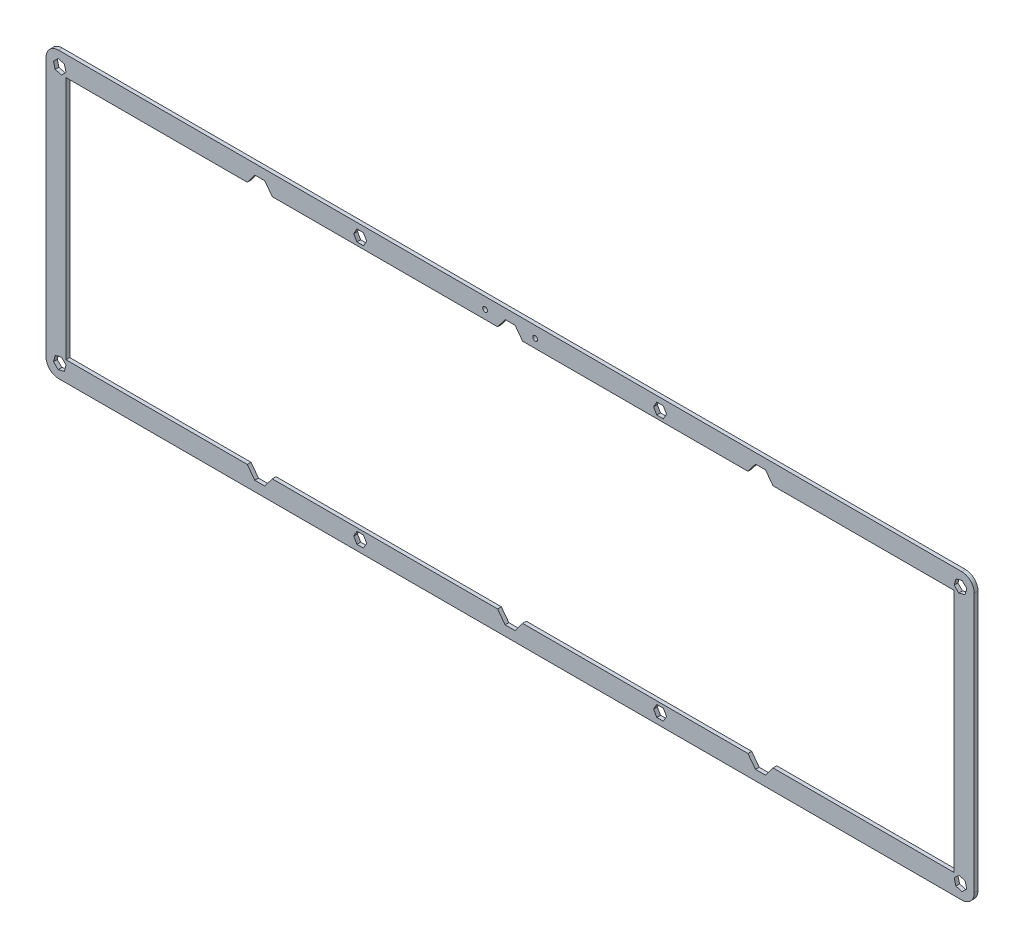
from build123d import *

# Parameters (mm, degrees)
MODEL_R             = 0.95
BOSS_EXTRUDE1_DEPTH = 1.5


with BuildPart() as part:
    # Model → Boss-Extrude1 (new body)
    with BuildSketch(Plane.XY):
        with BuildLine():
            Line((0, 108.6), (0, 5))
            ThreePointArc((0, 5), (1.464466094, 1.464466094), (5, 0))
            Line((5, 0), (365.775, 0))
            ThreePointArc((365.775, 0), (369.310533906, 1.464466094), (370.775, 5))
            Line((370.775, 5), (370.775, 108.6))
            ThreePointArc((370.775, 108.6), (369.310533906, 112.135533906), (365.775, 113.6))
            Line((365.775, 113.6), (5, 113.6))
            ThreePointArc((5, 113.6), (1.464466094, 112.135533906), (0, 108.6))
        make_face()
        with Locations((175.3875, 109.1)):
            Circle(MODEL_R, mode=Mode.SUBTRACT)
        with Locations((195.3875, 109.1)):
            Circle(MODEL_R, mode=Mode.SUBTRACT)
        Polygon((8, 8), (8, 105.6), (80.3875, 105.6), (83.3875, 109.6), (87.3875, 109.6), (90.3875, 105.6), (180.3875, 105.6), (183.3875, 109.6), (187.3875, 109.6), (190.3875, 105.6), (280.3875, 105.6), (283.3875, 109.6), (287.3875, 109.6), (290.3875, 105.6), (362.775, 105.6), (362.775, 8), (290.3875, 8), (287.3875, 4), (283.3875, 4), (280.3875, 8), (190.3875, 8), (187.3875, 4), (183.3875, 4), (180.3875, 8), (90.3875, 8), (87.3875, 4), (83.3875, 4), (80.3875, 8), align=None, mode=Mode.SUBTRACT)
        Polygon((365.947431604, 110.609548911), (367.784548911, 108.772431604), (367.112117307, 106.262882693), (364.602568396, 105.590451089), (362.765451089, 107.427568396), (363.437882693, 109.937117307), align=None, mode=Mode.SUBTRACT)
        Polygon((4.827568396, 110.609548911), (2.990451089, 108.772431604), (3.662882693, 106.262882693), (6.172431604, 105.590451089), (8.009548911, 107.427568396), (7.337117307, 109.937117307), align=None, mode=Mode.SUBTRACT)
        Polygon((365.947431604, 2.990451089), (367.784548911, 4.827568396), (367.112117307, 7.337117307), (364.602568396, 8.009548911), (362.765451089, 6.172431604), (363.437882693, 3.662882693), align=None, mode=Mode.SUBTRACT)
        Polygon((126.799038106, 2.25), (124.200961894, 2.25), (122.901923789, 4.5), (124.200961894, 6.75), (126.799038106, 6.75), (128.098076211, 4.5), align=None, mode=Mode.SUBTRACT)
        Polygon((4.827568396, 2.990451089), (2.990451089, 4.827568396), (3.662882693, 7.337117307), (6.172431604, 8.009548911), (8.009548911, 6.172431604), (7.337117307, 3.662882693), align=None, mode=Mode.SUBTRACT)
        Polygon((243.975961894, 2.25), (246.574038106, 2.25), (247.873076211, 4.5), (246.574038106, 6.75), (243.975961894, 6.75), (242.676923789, 4.5), align=None, mode=Mode.SUBTRACT)
        Polygon((126.799038106, 111.35), (124.200961894, 111.35), (122.901923789, 109.1), (124.200961894, 106.85), (126.799038106, 106.85), (128.098076211, 109.1), align=None, mode=Mode.SUBTRACT)
        Polygon((243.975961894, 111.35), (246.574038106, 111.35), (247.873076211, 109.1), (246.574038106, 106.85), (243.975961894, 106.85), (242.676923789, 109.1), align=None, mode=Mode.SUBTRACT)
    extrude(amount=BOSS_EXTRUDE1_DEPTH)


solid = part.part
